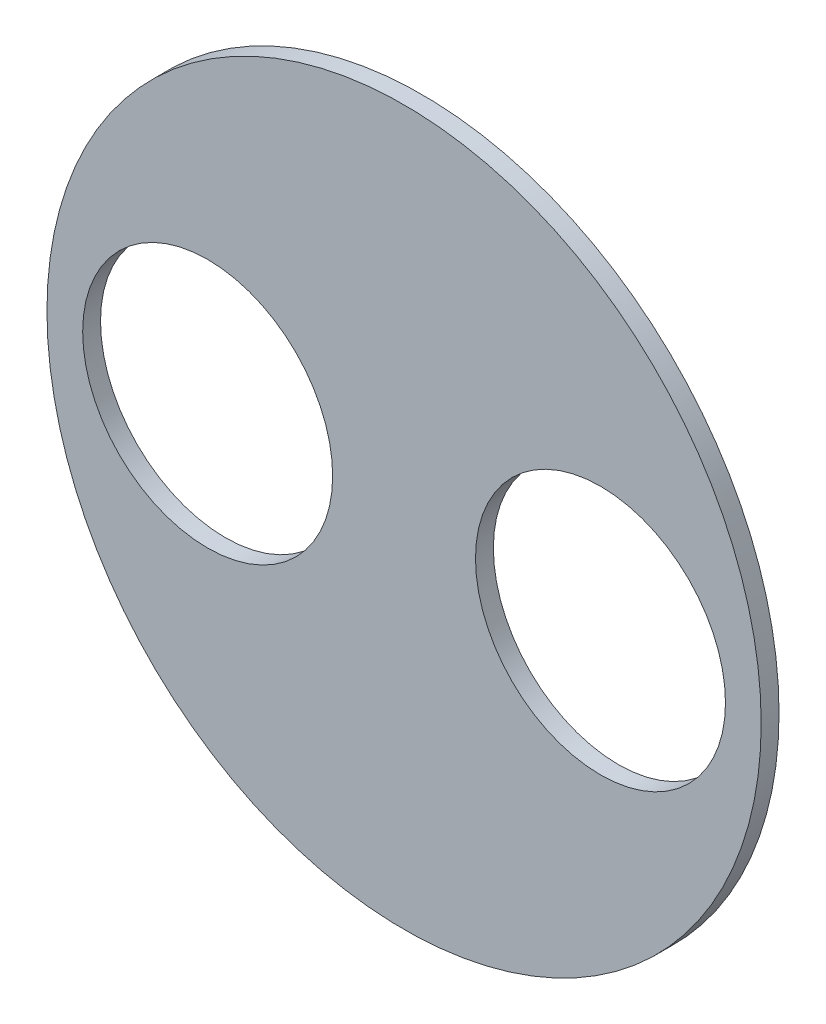
from build123d import *

# Parameters (mm, degrees)
SKETCH1_R           = 63.5
SKETCH1_R_2         = 22.225
BOSS_EXTRUDE1_DEPTH = 3.175


with BuildPart() as part:
    # Sketch1 → Boss-Extrude1 (new body)
    with BuildSketch(Plane.XY):
        Circle(SKETCH1_R)
        with Locations((34.925, 0)):
            Circle(SKETCH1_R_2, mode=Mode.SUBTRACT)
        with Locations((-34.925, 0)):
            Circle(SKETCH1_R_2, mode=Mode.SUBTRACT)
    extrude(amount=BOSS_EXTRUDE1_DEPTH)


solid = part.part
